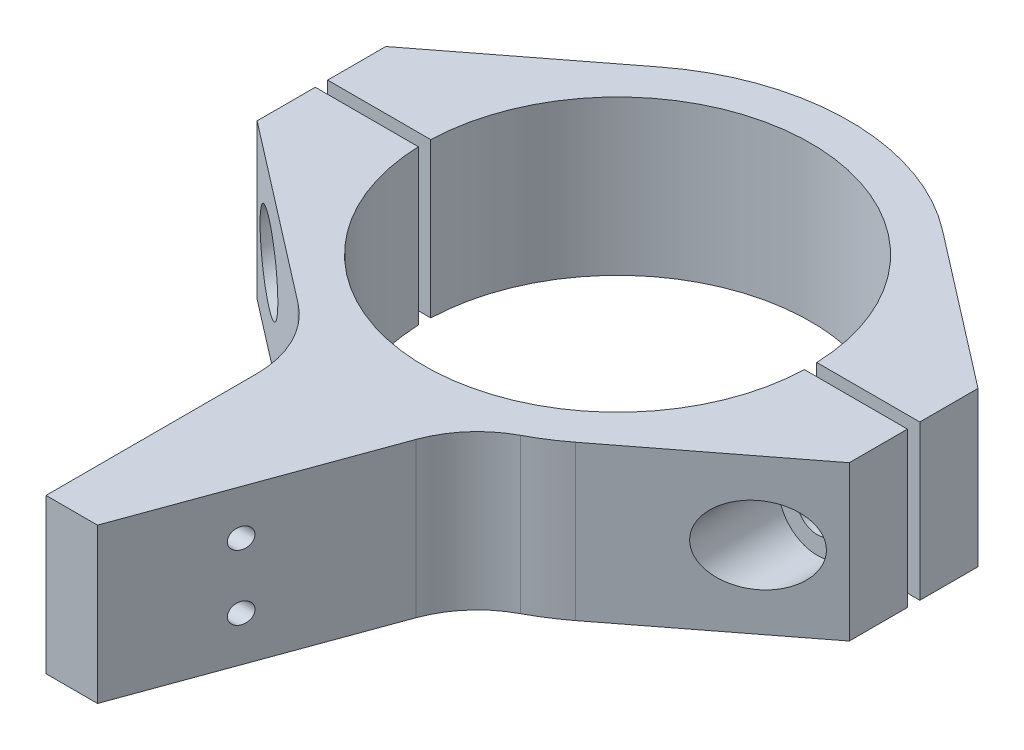
from build123d import *

# Parameters (mm, degrees)
SKETCH1_R               = 28.575
SKETCH1_R_2             = 23.8125
BOSS_EXTRUDE1_DEPTH     = 9.525
BOSS_EXTRUDE2_DEPTH     = 19.05
SKETCH3_W               = 73.025
SKETCH3_H               = 1.524
CUT_EXTRUDE1_DEPTH      = 1
CUT_EXTRUDE1_DEPTH_BACK = 20.05
BOSS_EXTRUDE3_DEPTH     = 19.05
M3X0_5_TAPPED_HOLE1_D   = 2.5
FILLET1_R               = 12.7


with BuildPart() as part:
    # Sketch1 → Boss-Extrude1 (new body, symmetric)
    with BuildSketch(Plane(origin=(0, 0, 0), x_dir=(1, 0, 0), z_dir=(0, 1, 0))):
        Circle(SKETCH1_R)
        Circle(SKETCH1_R_2, mode=Mode.SUBTRACT)
    extrude(amount=BOSS_EXTRUDE1_DEPTH, both=True)

    # Sketch2 → Boss-Extrude2 (add)
    with BuildSketch(Plane(origin=(0, 9.525, 0), x_dir=(1, 0, 0), z_dir=(0, 1, 0))):
        with BuildLine():
            Line((-17.442677512, 22.633683443), (-36.5125, 7.9375))
            Line((-36.5125, 7.9375), (-36.5125, -7.9375))
            Line((-36.5125, -7.9375), (-17.442677512, -22.633683443))
            ThreePointArc((-17.442677512, -22.633683443), (-28.575, 0), (-17.442677512, 22.633683443))
        make_face()
        with BuildLine():
            Line((36.5125, -7.9375), (17.442677512, -22.633683443))
            ThreePointArc((17.442677512, -22.633683443), (28.575, 0), (17.442677512, 22.633683443))
            Line((17.442677512, 22.633683443), (36.5125, 7.9375))
            Line((36.5125, 7.9375), (36.5125, -7.9375))
        make_face()
    extrude(amount=-BOSS_EXTRUDE2_DEPTH)

    # Sketch3 → Cut-Extrude1 (cut, two sides)
    with BuildSketch(Plane(origin=(0, 9.525, 0), x_dir=(1, 0, 0), z_dir=(0, 1, 0))) as cut_extrude1_sk:
        Rectangle(SKETCH3_W, SKETCH3_H)
    extrude(amount=CUT_EXTRUDE1_DEPTH, mode=Mode.SUBTRACT)
    extrude(cut_extrude1_sk.sketch, amount=-CUT_EXTRUDE1_DEPTH_BACK, mode=Mode.SUBTRACT)

    # Sketch4 → Cut-Revolve1 (revolve, cut)
    with BuildSketch(Plane(origin=(0, 0, 0), x_dir=(1, 0, 0), z_dir=(0, 1, 0))):
        Polygon((-27.603702439, -0.762), (-27.603702439, -5.5245), (-25.393902439, -5.5245), (-25.393902439, -16.506061637), (-30.156402439, -16.506061637), (-30.156402439, 15.282652702), (-26.981402439, 15.282652702), (-26.981402439, 0.762), align=None)
    cut_revolve1 = revolve(axis=Axis((-30.156402439, 0, -15.282652702), (0, 0, -1)), mode=Mode.SUBTRACT)

    # Mirror1: Cut-Revolve1 across plane
    add(cut_revolve1.mirror(Plane(origin=(0, 0, 0), x_dir=(0, 0, 1), z_dir=(1, 0, 0))), mode=Mode.SUBTRACT)

    # Sketch5 → Boss-Extrude3 (add)
    with BuildSketch(Plane(origin=(0, 9.525, 0), x_dir=(1, 0, 0), z_dir=(0, 1, 0))):
        with BuildLine():
            Line((9.161170255, -27.066650782), (-3.175, -60.96))
            Line((-3.175, -60.96), (-9.525, -60.96))
            Line((-9.525, -60.96), (-9.525, -34.981916191))
            ThreePointArc((-9.525, -34.981916191), (-10.828855385, -29.37675001), (-14.472698883, -24.922501327))
            Line((-14.472698883, -24.922501327), (-17.442677512, -22.633683443))
            ThreePointArc((-17.442677512, -22.633683443), (-4.696662695, -28.186379415), (9.161170255, -27.066650782))
        make_face()
    extrude(amount=-BOSS_EXTRUDE3_DEPTH)

    # M3x0.5 Tapped Hole1 (through all)
    with Locations(Plane(origin=(-9.525, 0, 0), x_dir=(0, 0, -1), z_dir=(-1, 0, 0))):
        with Locations((-47.970958095, -4), (-47.970958095, 4)):
            Hole(M3X0_5_TAPPED_HOLE1_D / 2)

    # Fillet1
    fillet1_edges = [part.edges().sort_by_distance(p)[0] for p in [
        (9.161170255, 0, 27.066650782),
    ]]
    fillet(fillet1_edges, radius=FILLET1_R)


solid = part.part
